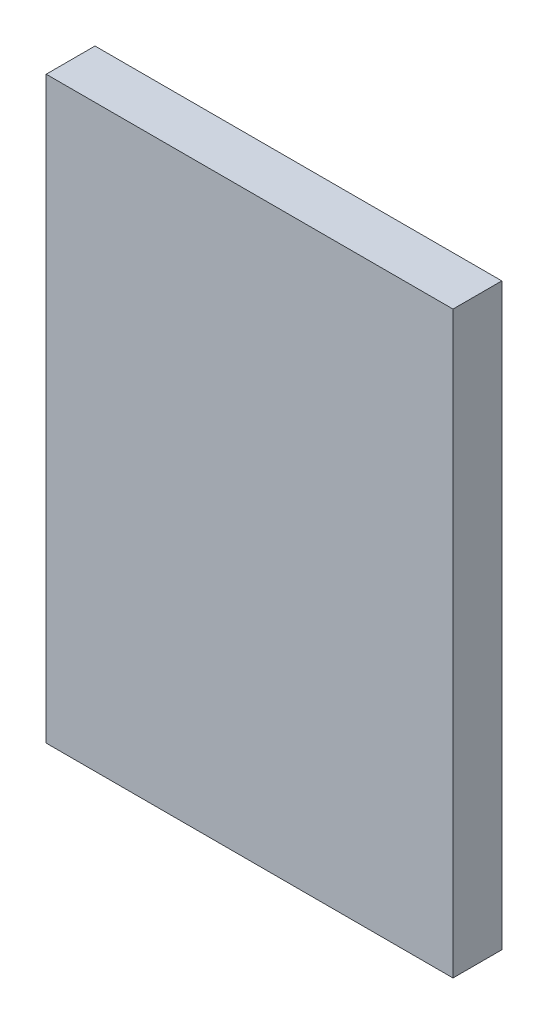
from build123d import *

# Parameters (mm, degrees)
SKETCH1_W           = 25
SKETCH1_H           = 35.6
BOSS_EXTRUDE1_DEPTH = 3


with BuildPart() as part:
    # Sketch1 → Boss-Extrude1 (new body)
    with BuildSketch(Plane.XY):
        with Locations((12.5, 17.8)):
            Rectangle(SKETCH1_W, SKETCH1_H)
    extrude(amount=BOSS_EXTRUDE1_DEPTH)


solid = part.part
